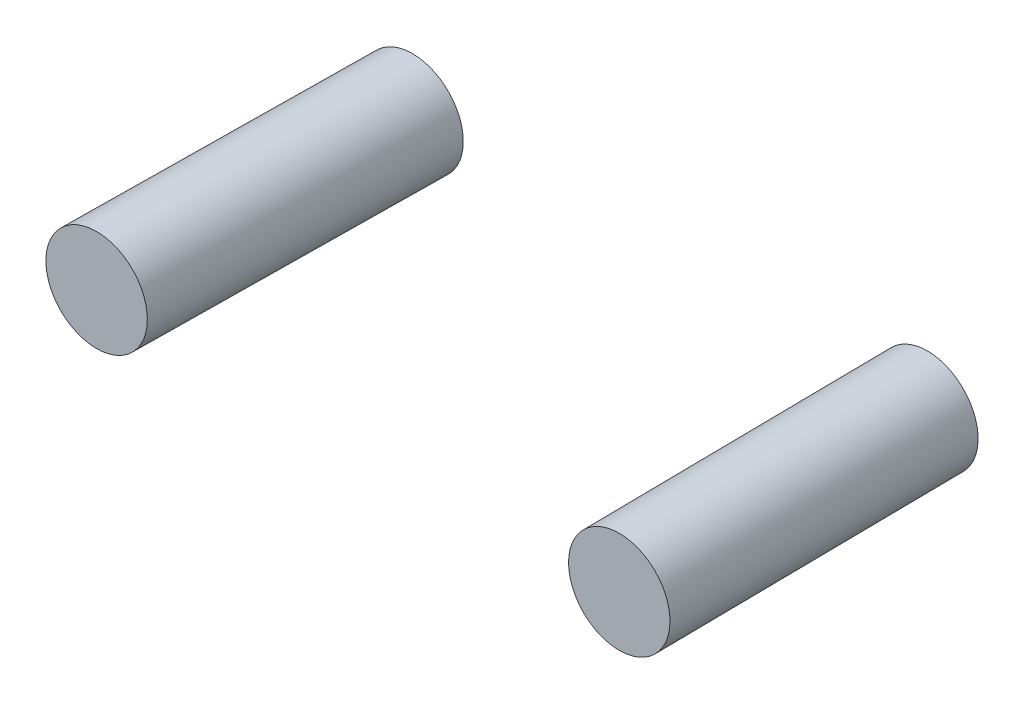
from build123d import *

# Parameters (mm, degrees)
SKETCH2_R = 16.51


with BuildPart() as part:
    # Sweep1: sweep along a path in Sketch1
    with BuildLine(Plane(origin=(0, 0, 0), x_dir=(1, 0, 0), z_dir=(0, 1, 0))) as sweep1_path:
        Line((-83.82, 101.6), (-85.09, 0))
    # Sketch2 → Sweep1 (sweep)
    with BuildSketch(Plane.XY):
        with Locations((-85.09, 0)):
            Circle(SKETCH2_R)
    sweep(path=sweep1_path.line)


with BuildPart() as body_2:
    # Mirror3: mirrored copy
    add(part.part.mirror(Plane(origin=(0, 0, 0), x_dir=(0, 0, 1), z_dir=(1, 0, 0))))


solid = Compound([part.part, body_2.part])
